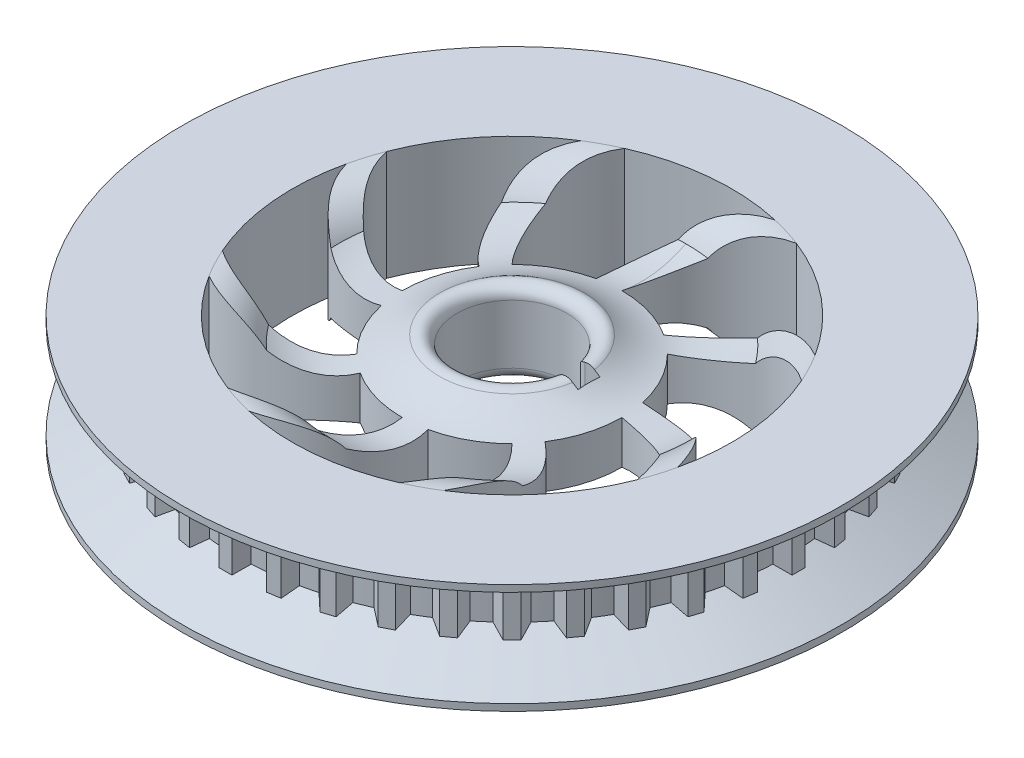
from build123d import *

# Parameters (mm, degrees)
SKETCH1_R           = 30
BOSS_EXTRUDE1_DEPTH = 10
CUT_EXTRUDE1_DEPTH  = 11.0000001
FILLET1_R           = 1
BOSS_EXTRUDE2_START = -2
BOSS_EXTRUDE2_DEPTH = 6
CIRPATTERN1_COUNT   = 40


with BuildPart() as part:
    # Sketch1 → Boss-Extrude1 (new body)
    with BuildSketch(Plane(origin=(0, 0, 0), x_dir=(1, 0, 0), z_dir=(0, 1, 0))):
        Circle(SKETCH1_R)
        with BuildLine():
            ThreePointArc((4.898979486, -1), (-5, 0), (4.898979486, 1))
            Line((4.898979486, 1), (7, 1))
            Line((7, 1), (7, -1))
            Line((7, -1), (4.898979486, -1))
        make_face(mode=Mode.SUBTRACT)
    extrude(amount=BOSS_EXTRUDE1_DEPTH)

    # Sketch2 → Cut-Revolve2 (revolve, cut)
    with BuildSketch(Plane.XY):
        Polygon((-25, 5), (-25, 6.5), (-30, 9.386751346), (-30, 0.613248654), (-25, 3.5), align=None)
        with BuildLine():
            ThreePointArc((-20, 10), (-17.628899876, 9.402031827), (-15.824936716, 7.751153681))
            ThreePointArc((-15.824936716, 7.751153681), (-10.015035728, 6.962514558), (-5, 10))
            Line((-5, 10), (-20, 10))
        make_face()
        with BuildLine():
            ThreePointArc((-5, 0), (-10.015035728, 3.037485442), (-15.824936716, 2.248846319))
            ThreePointArc((-15.824936716, 2.248846319), (-17.628899876, 0.597968173), (-20, 0))
            Line((-20, 0), (-5, 0))
        make_face()
    revolve(axis=Axis((0, 0, 0), (0, 1, 0)), mode=Mode.SUBTRACT)

    # Sketch4 → Cut-Extrude1 (cut, through all)
    with BuildSketch(Plane(origin=(0, 10, 0), x_dir=(1, 0, 0), z_dir=(0, 1, 0))):
        with BuildLine():
            ThreePointArc((-2.124788342, 9.771656692), (-0.654537058, 15.85153389), (4.422863289, 19.504827103))
            ThreePointArc((4.422863289, 19.504827103), (-1.919142053, 19.907709406), (-8.067393951, 18.30074192))
            ThreePointArc((-8.067393951, 18.30074192), (-9.545384017, 12.510575377), (-7.071067812, 7.071067812))
            ThreePointArc((-7.071067812, 7.071067812), (-4.792101593, 8.777001898), (-2.124788342, 9.771656692))
        make_face()
        with BuildLine():
            ThreePointArc((5.407152465, 8.412056956), (10.745899513, 11.671554698), (16.919432134, 10.664558887))
            ThreePointArc((16.919432134, 10.664558887), (12.719837959, 15.433914678), (7.236069743, 18.645087682))
            ThreePointArc((7.236069743, 18.645087682), (2.096706918, 15.595918453), (0, 10))
            ThreePointArc((0, 10), (2.817750028, 9.594805093), (5.407152465, 8.412056956))
        make_face()
        with BuildLine():
            ThreePointArc((19.504827103, -4.422863289), (19.875821267, -2.225248069), (20, 0))
            ThreePointArc((20, 0), (19.570575342, 4.122205817), (18.30074192, 8.067393951))
            ThreePointArc((18.30074192, 8.067393951), (12.510575377, 9.545384017), (7.071067812, 7.071067812))
            ThreePointArc((7.071067812, 7.071067812), (8.777001898, 4.792101593), (9.771656692, 2.124788342))
            ThreePointArc((9.771656692, 2.124788342), (15.85153389, 0.654537058), (19.504827103, -4.422863289))
        make_face()
        with BuildLine():
            ThreePointArc((10.664558887, -16.919432134), (15.433914678, -12.719837959), (18.645087682, -7.236069743))
            ThreePointArc((18.645087682, -7.236069743), (15.595918453, -2.096706918), (10, 0))
            ThreePointArc((10, 0), (9.594805093, -2.817750028), (8.412056956, -5.407152465))
            ThreePointArc((8.412056956, -5.407152465), (11.671554698, -10.745899513), (10.664558887, -16.919432134))
        make_face()
        with BuildLine():
            ThreePointArc((-4.422863289, -19.504827103), (1.919142053, -19.907709406), (8.067393951, -18.30074192))
            ThreePointArc((8.067393951, -18.30074192), (9.545384017, -12.510575377), (7.071067812, -7.071067812))
            ThreePointArc((7.071067812, -7.071067812), (4.792101593, -8.777001898), (2.124788342, -9.771656692))
            ThreePointArc((2.124788342, -9.771656692), (0.654537058, -15.85153389), (-4.422863289, -19.504827103))
        make_face()
        with BuildLine():
            ThreePointArc((-16.919432134, -10.664558887), (-12.719837959, -15.433914678), (-7.236069743, -18.645087682))
            ThreePointArc((-7.236069743, -18.645087682), (-2.096706918, -15.595918453), (0, -10))
            ThreePointArc((0, -10), (-2.817750028, -9.594805093), (-5.407152465, -8.412056956))
            ThreePointArc((-5.407152465, -8.412056956), (-10.745899513, -11.671554698), (-16.919432134, -10.664558887))
        make_face()
        with BuildLine():
            ThreePointArc((-9.771656692, -2.124788342), (-15.85153389, -0.654537058), (-19.504827103, 4.422863289))
            ThreePointArc((-19.504827103, 4.422863289), (-19.907709406, -1.919142053), (-18.30074192, -8.067393951))
            ThreePointArc((-18.30074192, -8.067393951), (-12.510575377, -9.545384017), (-7.071067812, -7.071067812))
            ThreePointArc((-7.071067812, -7.071067812), (-8.777001898, -4.792101593), (-9.771656692, -2.124788342))
        make_face()
        with BuildLine():
            ThreePointArc((-8.412056956, 5.407152465), (-11.671554698, 10.745899513), (-10.664558887, 16.919432134))
            ThreePointArc((-10.664558887, 16.919432134), (-15.433914678, 12.719837959), (-18.645087682, 7.236069743))
            ThreePointArc((-18.645087682, 7.236069743), (-15.595918453, 2.096706918), (-10, 0))
            ThreePointArc((-10, 0), (-9.594805093, 2.817750028), (-8.412056956, 5.407152465))
        make_face()
    extrude(amount=-CUT_EXTRUDE1_DEPTH, mode=Mode.SUBTRACT)

    # Fillet1
    fillet1_edges = [part.edges().sort_by_distance(p)[0] for p in [
        (4.898979486, 5, 1),
        (-0.50254481, 10, 4.974680765),
        (4.898979486, 5, -1),
        (-0.50254481, 0, 4.974680765),
    ]]
    fillet(fillet1_edges, radius=FILLET1_R)

    # Sketch5 → Boss-Extrude2 (add)
    with BuildSketch(Plane(origin=(0, 6, 0), x_dir=(-1, 0, 0), z_dir=(0, -1, 0)).offset(BOSS_EXTRUDE2_START)):
        Polygon((1.811531149, 23.954112003), (0.582180372, 26.08341001), (-0.582180372, 26.08341001), (-1.811531149, 23.954112003), align=None)
    boss_extrude2 = extrude(amount=BOSS_EXTRUDE2_DEPTH)

    # CirPattern1: Boss-Extrude2 ×40 about axis
    cirpattern1_axis = Axis((0, 0, 0), (0, 1, 0))
    for i in range(1, CIRPATTERN1_COUNT):
        add(boss_extrude2.rotate(cirpattern1_axis, i * 360 / CIRPATTERN1_COUNT))


solid = part.part
